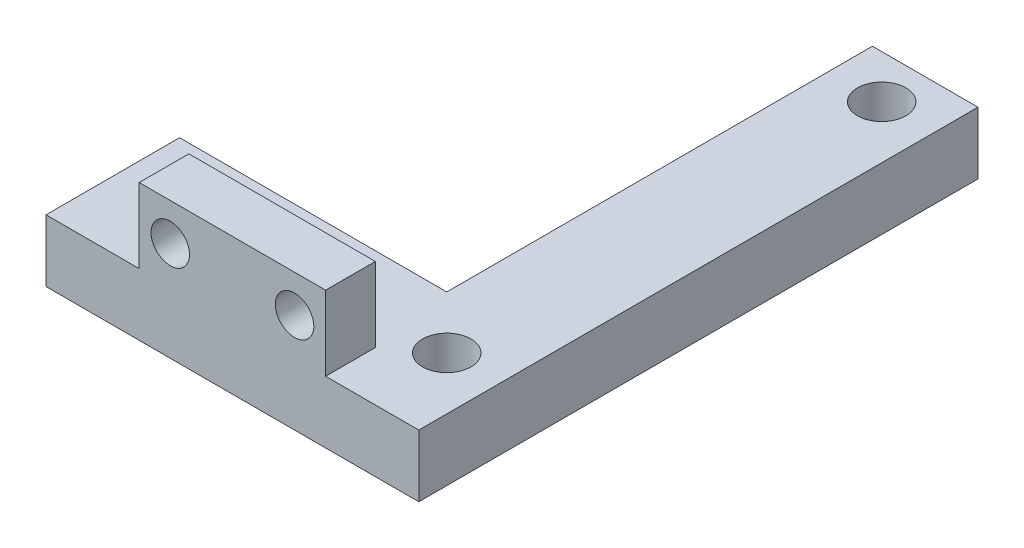
from build123d import *

# Parameters (mm, degrees)
SKETCH1_W           = 30
SKETCH1_H           = 45
BOSS_EXTRUDE1_DEPTH = 5
SKETCH2_R           = 1.95
SKETCH2_W           = 21.5
SKETCH2_H           = 34.25
CUT_EXTRUDE1_DEPTH  = 6
SKETCH3_W           = 15
SKETCH3_H           = 4
BOSS_EXTRUDE2_DEPTH = 6
SKETCH4_R           = 1.55
CUT_EXTRUDE2_DEPTH  = 5


with BuildPart() as part:
    # Sketch1 → Boss-Extrude1 (new body)
    with BuildSketch(Plane(origin=(0, 0, 0), x_dir=(1, 0, 0), z_dir=(0, 1, 0))):
        Rectangle(SKETCH1_W, SKETCH1_H)
    extrude(amount=BOSS_EXTRUDE1_DEPTH)

    # Sketch2 → Cut-Extrude1 (cut, through all)
    with BuildSketch(Plane(origin=(0, 5, 0), x_dir=(1, 0, 0), z_dir=(0, 1, 0))):
        with Locations((10.75, 19)):
            Circle(SKETCH2_R)
        with Locations((10.75, -16)):
            Circle(SKETCH2_R)
        with Locations((-10.75, -16)):
            Circle(SKETCH2_R)
        with Locations((-4.25, 5.375)):
            Rectangle(SKETCH2_W, SKETCH2_H)
    extrude(amount=-CUT_EXTRUDE1_DEPTH, mode=Mode.SUBTRACT)

    # Sketch3 → Boss-Extrude2 (add)
    with BuildSketch(Plane(origin=(0, 5, 0), x_dir=(1, 0, 0), z_dir=(0, 1, 0))):
        with Locations((0, -20.5)):
            Rectangle(SKETCH3_W, SKETCH3_H)
    extrude(amount=BOSS_EXTRUDE2_DEPTH)

    # Sketch4 → Cut-Extrude2 (cut, through all)
    with BuildSketch(Plane(origin=(0, 0, 18.5), x_dir=(-1, 0, 0), z_dir=(0, 0, -1))):
        with Locations((-5, 8)):
            Circle(SKETCH4_R)
        with Locations((5, 8)):
            Circle(SKETCH4_R)
    extrude(amount=-CUT_EXTRUDE2_DEPTH, mode=Mode.SUBTRACT)


solid = part.part
